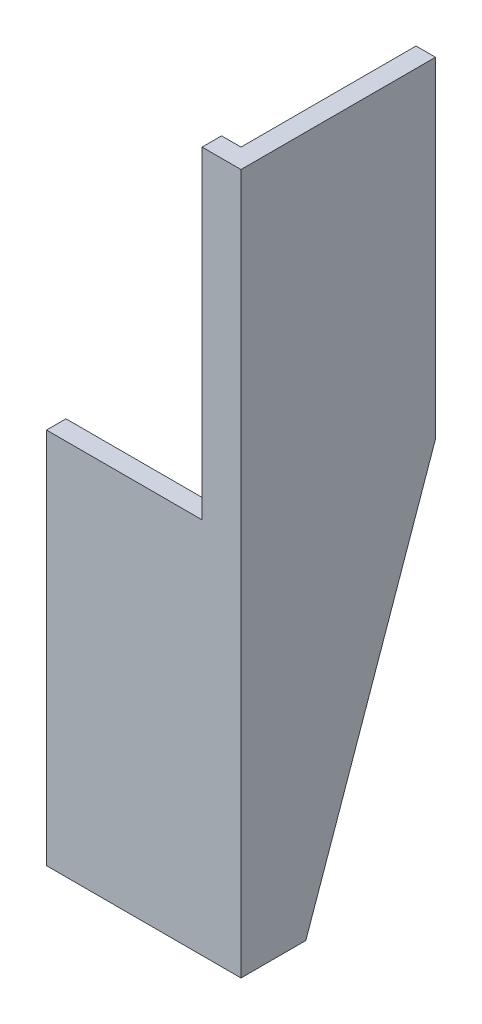
from build123d import *

# Parameters (mm, degrees)
SALIENTE_EXTRUIR1_DEPTH = 180
CORTAR_EXTRUIR1_DEPTH   = 5
CROQUIS3_W              = 40
CROQUIS3_H              = 83
CORTAR_EXTRUIR2_DEPTH   = 5


with BuildPart() as part:
    # Croquis1 → Saliente-Extruir1 (new body)
    with BuildSketch(Plane(origin=(0, 0, 0), x_dir=(1, 0, 0), z_dir=(0, 1, 0))):
        Polygon((0, 0), (-50, 0), (-50, 5), (-5, 5), (-5, 50), (0, 50), align=None)
    extrude(amount=SALIENTE_EXTRUIR1_DEPTH)

    # Croquis2 → Cortar-Extruir1 (cut)
    with BuildSketch(Plane(origin=(0, 0, 0), x_dir=(0, 0, -1), z_dir=(1, 0, 0))):
        Polygon((50, 95), (16.666666667, 0), (50, 0), align=None)
    extrude(amount=-CORTAR_EXTRUIR1_DEPTH, mode=Mode.SUBTRACT)

    # Croquis3 → Cortar-Extruir2 (cut)
    with BuildSketch(Plane.XY):
        with Locations((-30, 138.5)):
            Rectangle(CROQUIS3_W, CROQUIS3_H)
    extrude(amount=-CORTAR_EXTRUIR2_DEPTH, mode=Mode.SUBTRACT)


solid = part.part
